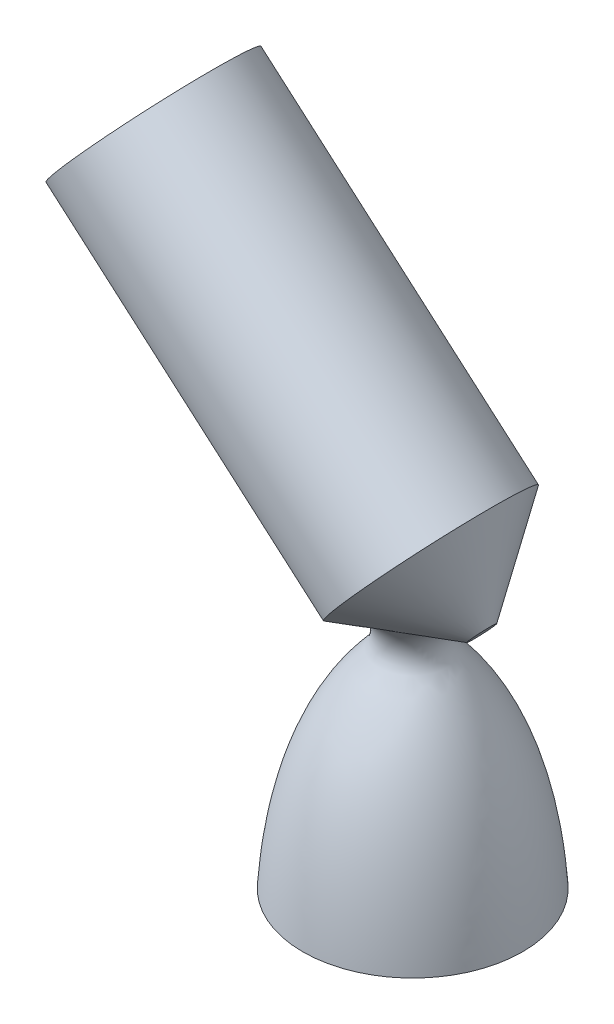
from build123d import *


with BuildPart() as part:
    # Sketch2 → Revolve1 (revolve)
    with BuildSketch(Plane.XY):
        Polygon((1030.061278696, -216.58443678), (959.657201148, -155.39542863), (972.314875011, -140.831508096), (1031.82096691, -192.548949314), (1031.82096691, -214.559739384), align=None)
    revolve(axis=Axis((1030.061278696, -216.58443678, 0), (-0.754774987, 0.655983779, 0)))

    # Sketch1 → Revolve2 (revolve)
    with BuildSketch(Plane.XY, mode=Mode.PRIVATE) as revolve2_sk:
        with BuildLine():
            Line((1034.963586572, -271.3945274), (1038.828918992, -271.3945274))
            add(Edge.make_bspline(
                [(1038.828918992, -271.3945274), (1037.873448174, -256.436961098), (1033.932423541, -239.028318184), (1022.04554778, -226.197270809), (1021.385558194, -223.249921116), (1023.46164644, -215.880421657), (1031.802541842, -213.509952537), (1030.500568899, -206.266042019)],
                knots=[0, 0, 0, 0, 0.648973555, 0.689713178, 0.725948802, 0.770741807, 1, 1, 1, 1], degree=3))
            Line((1030.500568899, -206.266042019), (1015.25039123, -206.266042019))
            Line((1015.25039123, -206.266042019), (1015.25039123, -232.741203199))
            Line((1015.25039123, -232.741203199), (1034.963586572, -271.3945274))
        make_face()
    revolve(revolve2_sk.sketch.rotate(Axis((1015.25039123, -199.885877629, 0), (0, -1, 0)), 270), axis=Axis((1015.25039123, -199.885877629, 0), (0, -1, 0)))  # turned: the seam where the file's is


solid = part.part
